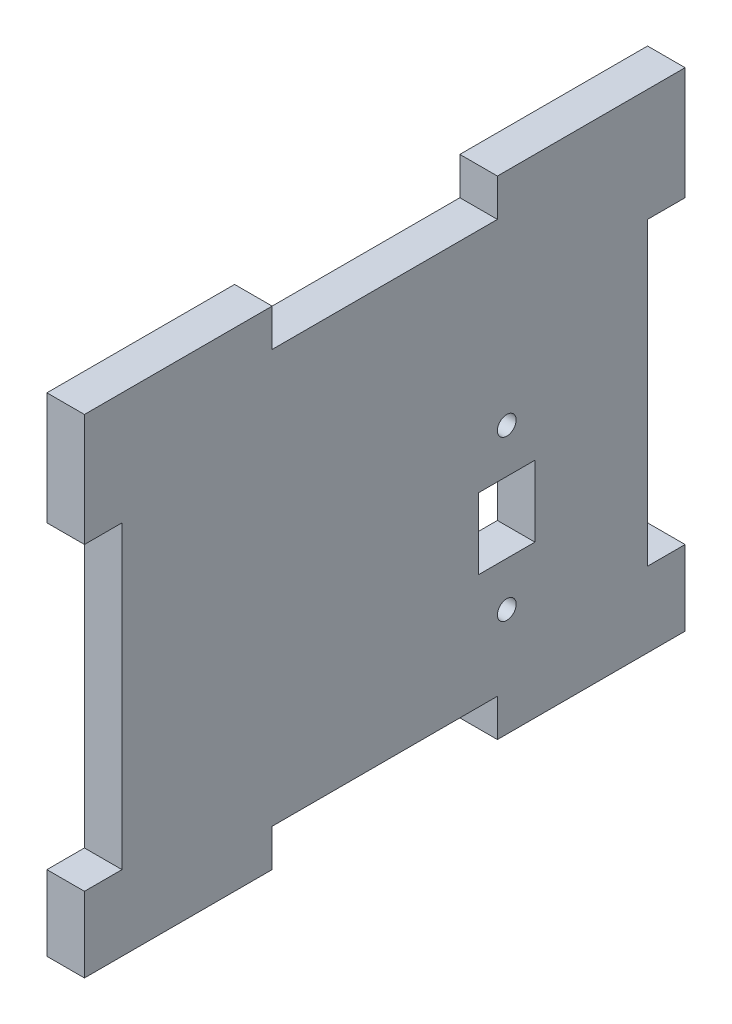
from build123d import *

# Parameters (mm, degrees)
BOSS_EXTRUDE1_DEPTH = 6.35
SKETCH2_R           = 1.5875
SKETCH2_W           = 9.525
SKETCH2_H           = 12.0015
CUT_EXTRUDE1_DEPTH  = 6.35


with BuildPart() as part:
    # Sketch1 → Boss-Extrude1 (new body)
    with BuildSketch(Plane(origin=(0, 0, 0), x_dir=(0, 0, -1), z_dir=(1, 0, 0))):
        Polygon((-50.8, -28.575), (-50.8, -41.275), (-19.05, -41.275), (-19.05, -34.925), (19.05, -34.925), (19.05, -41.275), (50.8, -41.275), (50.8, -28.575), (44.45, -28.575), (44.45, 22.225), (50.8, 22.225), (50.8, 41.275), (19.05, 41.275), (19.05, 34.925), (-19.05, 34.925), (-19.05, 41.275), (-50.8, 41.275), (-50.8, 22.225), (-44.45, 22.225), (-44.45, -28.575), align=None)
    extrude(amount=BOSS_EXTRUDE1_DEPTH)

    # Sketch2 → Cut-Extrude1 (cut)
    with BuildSketch(Plane(origin=(6.35, 95.4107123, 69.821382876), x_dir=(0, 0, -1), z_dir=(1, 0, 0))):
        with Locations((90.458882876, -118.4294623)):
            Circle(SKETCH2_R)
        with Locations((90.458882876, -91.4419623)):
            Circle(SKETCH2_R)
        with Locations((90.458882876, -104.9357123)):
            Rectangle(SKETCH2_W, SKETCH2_H)
    extrude(amount=-CUT_EXTRUDE1_DEPTH, mode=Mode.SUBTRACT)


solid = part.part
